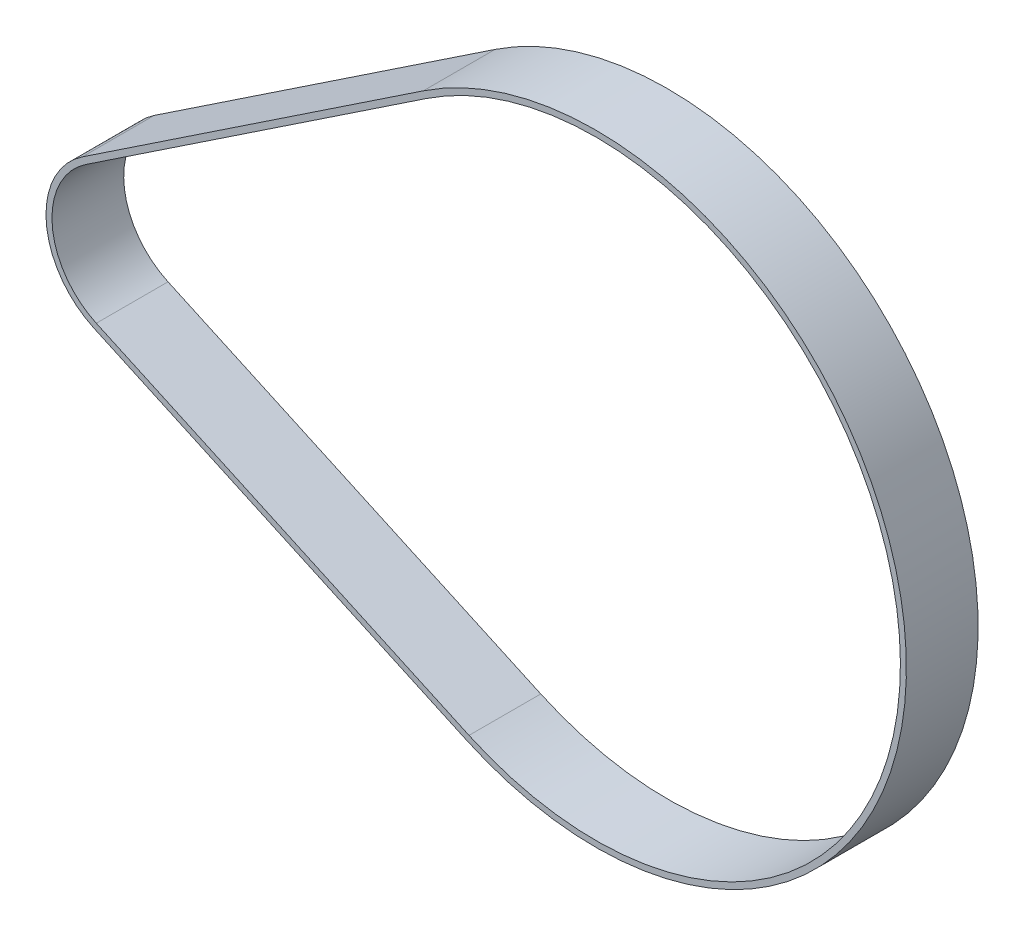
from build123d import *

# Parameters (mm, degrees)
BOSS_EXTRUDE1_DEPTH      = 4
BOSS_EXTRUDE1_DEPTH_BACK = 2


with BuildPart() as part:
    # Sketch3 → Boss-Extrude1 (new body, two sides)
    with BuildSketch(Plane.XY) as boss_extrude1_sk:
        with BuildLine():
            Line((-3.803846336, 5.696775672), (24.708284265, 24.734871916))
            ThreePointArc((24.708284265, 24.734871916), (65.032506622, 5.199104), (28.324251817, -20.49512037))
            Line((28.324251817, -20.49512037), (-2.850444576, -6.228761171))
            ThreePointArc((-2.850444576, -6.228761171), (-6.828213831, -0.545889982), (-3.803846336, 5.696775672))
        make_face()
        with BuildLine():
            Line((-3.526193319, 5.28095263), (24.985937282, 24.319048874))
            ThreePointArc((24.985937282, 24.319048874), (64.534096854, 5.159258016), (28.532313465, -20.04046627))
            Line((28.532313465, -20.04046627), (-2.642382928, -5.774107071))
            ThreePointArc((-2.642382928, -5.774107071), (-6.329804063, -0.506043998), (-3.526193319, 5.28095263))
        make_face(mode=Mode.SUBTRACT)
    extrude(amount=BOSS_EXTRUDE1_DEPTH)
    extrude(boss_extrude1_sk.sketch, amount=-BOSS_EXTRUDE1_DEPTH_BACK)


solid = part.part
